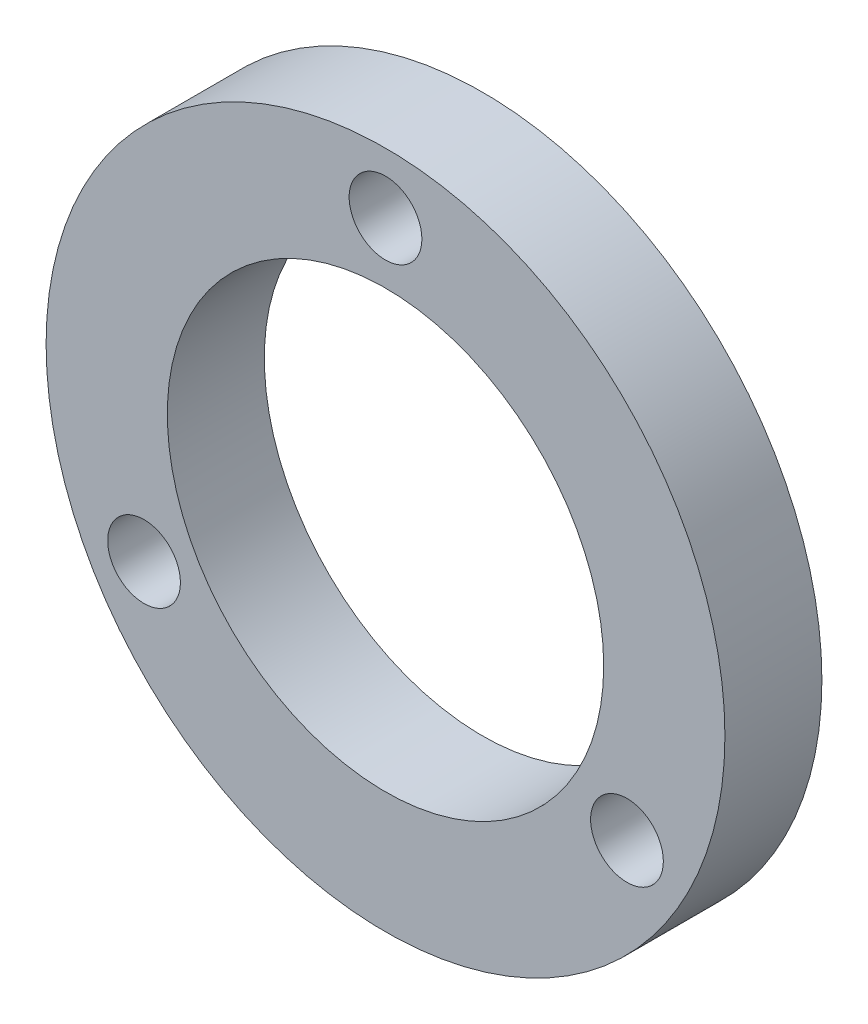
from build123d import *

# Parameters (mm, degrees)
SKETCH_2_R      = 7
SKETCH_2_R_2    = 4.5
SKETCH_2_R_3    = 0.75
EXTRUDE_1_DEPTH = 2


with BuildPart() as part:
    # 草圖2 → 填料-伸長1 (new body)
    with BuildSketch(Plane.XY):
        Circle(SKETCH_2_R)
        Circle(SKETCH_2_R_2, mode=Mode.SUBTRACT)
        with Locations((0, 5.75)):
            Circle(SKETCH_2_R_3, mode=Mode.SUBTRACT)
        with Locations((4.979646072, -2.875)):
            Circle(SKETCH_2_R_3, mode=Mode.SUBTRACT)
        with Locations((-4.979646072, -2.875)):
            Circle(SKETCH_2_R_3, mode=Mode.SUBTRACT)
    extrude(amount=EXTRUDE_1_DEPTH)


solid = part.part
